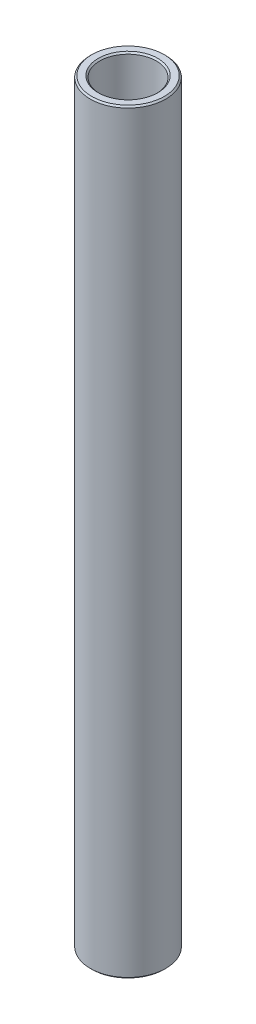
from build123d import *

# Parameters (mm, degrees)
SKETCH1_W     = 1.5875
SKETCH1_H     = 127.187133447
CHAMFER1_SIZE = 0.254


with BuildPart() as part:
    # Sketch1 → Revolve1 (revolve)
    with BuildSketch(Plane.XY):
        with Locations((5.55625, 134.237261689)):
            Rectangle(SKETCH1_W, SKETCH1_H)
    revolve(axis=Axis((0, 61.118694965, 0), (0, 1, 0)))

    # Chamfer1
    chamfer1_edges = [part.edges().sort_by_distance(p)[0] for p in [
        (-6.35, 70.643694965, 0),
        (-6.35, 197.830828412, 0),
        (-4.7625, 197.830828412, 0),
        (-4.7625, 70.643694965, 0),
    ]]
    chamfer(chamfer1_edges, length=CHAMFER1_SIZE)


solid = part.part
